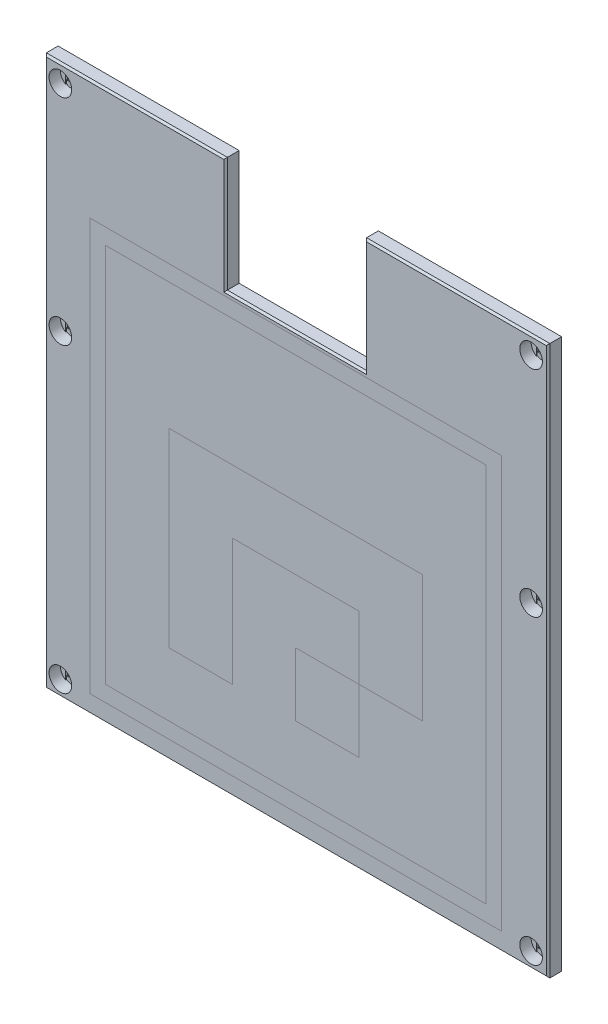
from build123d import *

# Parameters (mm, degrees)
SKETCH1_R             = 1.35
BOSS_EXTRUDE1_DEPTH   = 3
SKETCH3_R             = 2.5
CUT_EXTRUDE1_DEPTH    = 2.5
SKETCH4_W             = 91
SKETCH4_H             = 85
CUT_EXTRUDE2_DEPTH    = 1.5
CUT_EXTRUDE3_DEPTH    = 0.2
SKETCH6_W             = 2.7
SKETCH6_H             = 2.7
CUT_EXTRUDE4_DEPTH    = 0.2
CHAMFER1_SIZE         = 0.4
SKETCH7_W             = 91
SKETCH7_H             = 91
CUT_EXTRUDE5_DEPTH    = 0.4
SKETCH8_W             = 91
SKETCH8_H             = 91
SKETCH8_W_2           = 84
SKETCH8_H_2           = 84
BOSS_EXTRUDE2_DEPTH   = 0.4
SKETCH9_W             = 14
SKETCH9_H             = 14
CUT_EXTRUDE6_DEPTH    = 0.4
SKETCH10_W            = 14
SKETCH10_H            = 14
BOSS_EXTRUDE3_DEPTH   = 0.4
BOSS_EXTRUDE3_2_DEPTH = 0.4


with BuildPart() as part:
    # Sketch1 → Boss-Extrude1 (new body)
    with BuildSketch(Plane.XY):
        Polygon((-15.5, 53.9), (-15.5, 28.5), (15.25, 28.5), (15.25, 53.9), (55.75, 53.9), (55.75, -67.5), (-55.5, -67.5), (-55.5, 53.9), align=None)
        with Locations((-52, 50)):
            Circle(SKETCH1_R, mode=Mode.SUBTRACT)
        with Locations((-52, 2.6)):
            Circle(SKETCH1_R, mode=Mode.SUBTRACT)
        with Locations((-52, -64)):
            Circle(SKETCH1_R, mode=Mode.SUBTRACT)
        with Locations((52, 50)):
            Circle(SKETCH1_R, mode=Mode.SUBTRACT)
        with Locations((52, 2.6)):
            Circle(SKETCH1_R, mode=Mode.SUBTRACT)
        with Locations((52, -64)):
            Circle(SKETCH1_R, mode=Mode.SUBTRACT)
    extrude(amount=BOSS_EXTRUDE1_DEPTH)

    # Sketch3 → Cut-Extrude1 (cut)
    with BuildSketch(Plane.XY.offset(3)):
        with Locations((-52, 50)):
            Circle(SKETCH3_R)
        with Locations((-52, 2.6)):
            Circle(SKETCH3_R)
        with Locations((-52, -64)):
            Circle(SKETCH3_R)
        with Locations((52, -64)):
            Circle(SKETCH3_R)
        with Locations((52, 2.6)):
            Circle(SKETCH3_R)
        with Locations((52, 50)):
            Circle(SKETCH3_R)
    extrude(amount=-CUT_EXTRUDE1_DEPTH, mode=Mode.SUBTRACT)

    # Sketch4 → Cut-Extrude2 (cut)
    with BuildSketch(Plane(origin=(0, 0, 0), x_dir=(-1, 0, 0), z_dir=(0, 0, -1))):
        with Locations((0, -15)):
            Rectangle(SKETCH4_W, SKETCH4_H)
    extrude(amount=-CUT_EXTRUDE2_DEPTH, mode=Mode.SUBTRACT)

    # Sketch5 → Cut-Extrude3 (cut)
    with BuildSketch(Plane.XY.offset(0.5)):
        with BuildLine():
            Line((-53.35, 47.895837459), (-53.35, 52.104162541))
            ThreePointArc((-53.35, 52.104162541), (-52, 52.5), (-50.65, 52.104162541))
            Line((-50.65, 52.104162541), (-50.65, 47.895837459))
            ThreePointArc((-50.65, 47.895837459), (-52, 47.5), (-53.35, 47.895837459))
        make_face()
        with BuildLine():
            Line((-53.35, 0.495837459), (-53.35, 4.704162541))
            ThreePointArc((-53.35, 4.704162541), (-52, 5.1), (-50.65, 4.704162541))
            Line((-50.65, 4.704162541), (-50.65, 0.495837459))
            ThreePointArc((-50.65, 0.495837459), (-52, 0.1), (-53.35, 0.495837459))
        make_face()
        with BuildLine():
            Line((-53.35, -66.104162541), (-53.35, -61.895837459))
            ThreePointArc((-53.35, -61.895837459), (-52, -61.5), (-50.65, -61.895837459))
            Line((-50.65, -61.895837459), (-50.65, -66.104162541))
            ThreePointArc((-50.65, -66.104162541), (-52, -66.5), (-53.35, -66.104162541))
        make_face()
    cut_extrude3 = extrude(amount=-CUT_EXTRUDE3_DEPTH, mode=Mode.SUBTRACT)

    # Sketch6 → Cut-Extrude4 (cut)
    with BuildSketch(Plane.XY.offset(0.3)):
        with Locations((-52, -64)):
            Rectangle(SKETCH6_W, SKETCH6_H)
        with Locations((-52, 2.6)):
            Rectangle(SKETCH6_W, SKETCH6_H)
        with Locations((-52, 50)):
            Rectangle(SKETCH6_W, SKETCH6_H)
    cut_extrude4 = extrude(amount=-CUT_EXTRUDE4_DEPTH, mode=Mode.SUBTRACT)

    # Mirror1: Cut-Extrude3, Cut-Extrude4 across plane
    add(cut_extrude3.mirror(Plane(origin=(0, 0, 0), x_dir=(0, 0, 1), z_dir=(1, 0, 0))), mode=Mode.SUBTRACT)
    add(cut_extrude4.mirror(Plane(origin=(0, 0, 0), x_dir=(0, 0, 1), z_dir=(1, 0, 0))), mode=Mode.SUBTRACT)

    # Chamfer1
    chamfer1_edges = [part.edges().sort_by_distance(p)[0] for p in [
        (55.75, -6.8, 3),
        (35.5, 53.9, 3),
        (15.25, 41.2, 3),
        (-0.125, 28.5, 3),
        (-15.5, 41.2, 3),
        (-35.5, 53.9, 3),
        (-55.5, -6.8, 3),
        (0.125, -67.5, 3),
    ]]
    chamfer(chamfer1_edges, length=CHAMFER1_SIZE)

    # Sketch7 → Cut-Extrude5 (cut)
    with BuildSketch(Plane.XY.offset(3)):
        with Locations((0, -18)):
            Rectangle(SKETCH7_W, SKETCH7_H)
        Polygon((28, 24), (42, 24), (42, 10), (42, -4), (42, -18), (42, -32), (42, -46), (42, -60), (28, -60), (14, -60), (0, -60), (-14, -60), (-28, -60), (-42, -60), (-42, -46), (-42, -32), (-42, -18), (-42, -4), (-42, 10), (-42, 24), (-28, 24), (-14, 24), (0, 24), (14, 24), align=None, mode=Mode.SUBTRACT)
    extrude(amount=-CUT_EXTRUDE5_DEPTH, mode=Mode.SUBTRACT)

    # Sketch9 → Cut-Extrude6 (cut)
    with BuildSketch(Plane.XY.offset(3)):
        with Locations((7, -39)):
            Rectangle(SKETCH9_W, SKETCH9_H)
        Polygon((-28, -18), (-28, -32), (-28, -46), (-14, -46), (-14, -32), (-14, -18), (0, -18), (14, -18), (14, -32), (28, -32), (28, -18), (28, -4), (14, -4), (0, -4), (-14, -4), (-28, -4), align=None)
    extrude(amount=-CUT_EXTRUDE6_DEPTH, mode=Mode.SUBTRACT)


with BuildPart() as body_2:
    # Sketch8 → Boss-Extrude2 (new body)
    with BuildSketch(Plane.XY.offset(2.6)):
        with Locations((0, -18)):
            Rectangle(SKETCH8_W, SKETCH8_H)
        with Locations((0, -18)):
            Rectangle(SKETCH8_W_2, SKETCH8_H_2, mode=Mode.SUBTRACT)
    extrude(amount=BOSS_EXTRUDE2_DEPTH)


with BuildPart() as body_3:
    # Sketch10 → Boss-Extrude3 (new body)
    with BuildSketch(Plane.XY.offset(2.6)):
        with Locations((7, -39)):
            Rectangle(SKETCH10_W, SKETCH10_H)
    extrude(amount=BOSS_EXTRUDE3_DEPTH)


with BuildPart() as body_4:
    # Sketch10 → Boss-Extrude3 2 (new body)
    with BuildSketch(Plane.XY.offset(2.6)):
        Polygon((14, -18), (14, -32), (28, -32), (28, -4), (-28, -4), (-28, -46), (-14, -46), (-14, -18), align=None)
    extrude(amount=BOSS_EXTRUDE3_2_DEPTH)


solid = Compound([part.part, body_2.part, body_3.part, body_4.part])
